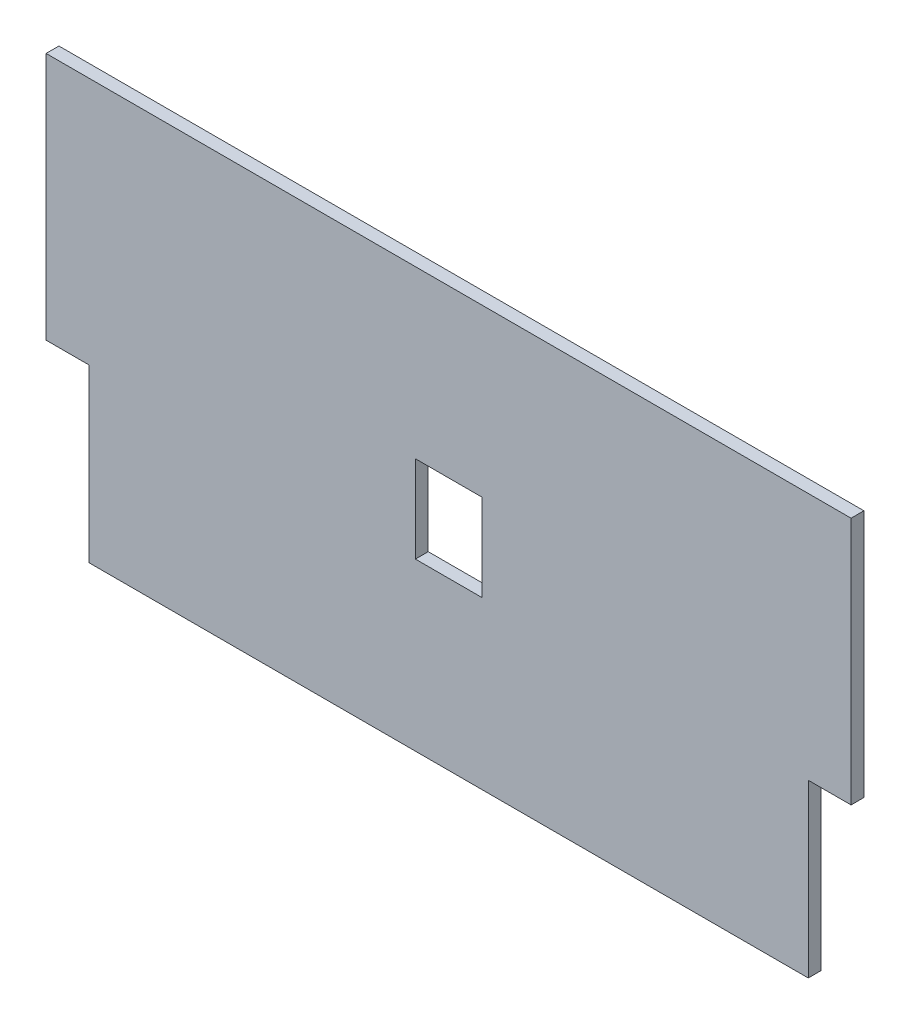
from build123d import *

# Parameters (mm, degrees)
RESSALTO_EXTRUS_O1_DEPTH = 1.5
ESBO_O2_W                = 15.5
ESBO_O2_H                = 20.3
CORTE_EXTRUS_O1_DEPTH    = 3


with BuildPart() as part:
    # Esboço1 → Ressalto-extrusão1 (new body, symmetric)
    with BuildSketch(Plane.XY):
        Polygon((-94, 0), (94, 0), (94, -58), (84, -58), (84, -98), (-84, -98), (-84, -58), (-94, -58), align=None)
    extrude(amount=RESSALTO_EXTRUS_O1_DEPTH, both=True)

    # Esboço2 → Corte-extrusão1 (cut)
    with BuildSketch(Plane.XY.offset(1.5)):
        with Locations((0, -49)):
            Rectangle(ESBO_O2_W, ESBO_O2_H)
    extrude(amount=-CORTE_EXTRUS_O1_DEPTH, mode=Mode.SUBTRACT)


solid = part.part
